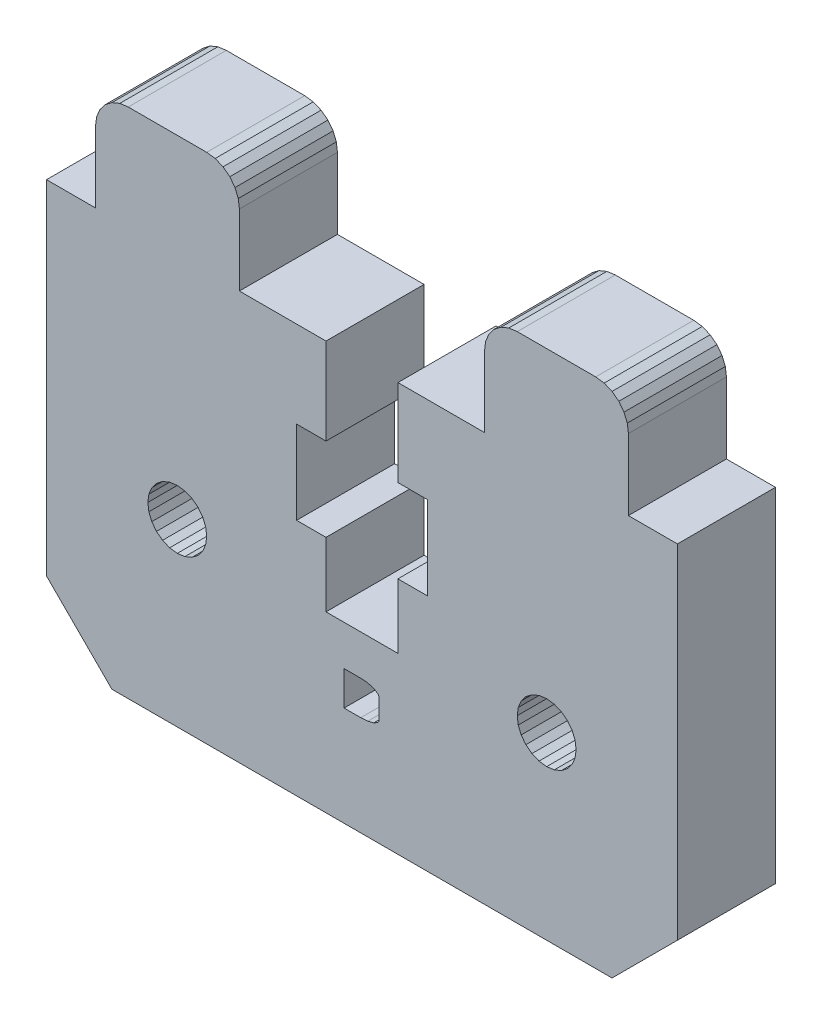
from build123d import *

# Parameters (mm, degrees)
BOSS_EXTRUDE1_DEPTH = 6


with BuildPart() as part:
    # Sketch1 → Boss-Extrude1 (new body)
    with BuildSketch(Plane.XY):
        Polygon((362.236464916, 316.694481551), (361.822251354, 316.376644305), (361.504414109, 315.962430743), (361.304613264, 315.480068833), (361.236464916, 314.962430743), (361.236464916, 310.612432852), (355.936467662, 310.612432852), (355.936467662, 305.31243403), (357.736465893, 305.31243403), (357.736465893, 300.212436266), (355.936467662, 300.212436266), (355.936467662, 296.262436443), (351.53646299, 296.262436443), (351.53646299, 300.212436266), (349.736464758, 300.212436266), (349.736464758, 305.31243403), (351.53646299, 305.31243403), (351.53646299, 310.612432852), (346.236470983, 310.612432852), (346.236470983, 314.962430743), (346.168322636, 315.480068833), (345.968521791, 315.962430743), (345.650684545, 316.376644305), (345.236470983, 316.694481551), (344.754109073, 316.894282396), (344.236470983, 316.962430743), (339.436475018, 316.962430743), (338.918836928, 316.894282396), (338.436475018, 316.694481551), (338.022261456, 316.376644305), (337.70442421, 315.962430743), (337.504623365, 315.480068833), (337.436475018, 314.962430743), (337.436475018, 310.612432852), (334.436475018, 310.612432852), (334.436475018, 289.612432852), (338.436475018, 285.612432852), (369.036459359, 285.612432852), (373.036459359, 289.612432852), (373.036459359, 310.612432852), (370.036459359, 310.612432852), (370.036459359, 314.962430743), (369.968311011, 315.480068833), (369.768510166, 315.962430743), (369.450672921, 316.376644305), (369.036459359, 316.694481551), (368.554097449, 316.894282396), (368.036459359, 316.962430743), (363.236464916, 316.962430743), (362.718826826, 316.894282396), align=None)
        Polygon((354.093152218, 291.74838599), (353.659993157, 291.717951777), (352.642224483, 291.717951777), (352.642224483, 291.718142326), (352.642224483, 293.809653378), (353.659993157, 293.809653378), (354.093152218, 293.774526901), (354.456082144, 293.669147471), (354.701943662, 293.513820442), (354.763409042, 293.425041085), (354.783897502, 293.328851168), (354.783897502, 292.161406427), (354.783897502, 292.161263515), (354.763442776, 292.066382302), (354.763409042, 292.066225822), (354.701943662, 291.980950777), (354.456082144, 291.839688629), align=None, mode=Mode.SUBTRACT)
        Polygon((340.877629291, 297.512432852), (341.163682812, 297.885225058), (341.536475018, 298.171278579), (341.970600737, 298.351099339), (342.436475018, 298.412432852), (342.902349299, 298.351099339), (343.336475018, 298.171278579), (343.709267224, 297.885225058), (343.995320745, 297.512432852), (344.175141505, 297.078307133), (344.236475018, 296.612432852), (344.175141505, 296.146558571), (343.995320745, 295.712432852), (343.709267224, 295.339640646), (343.336475018, 295.053587125), (342.902349299, 294.873766365), (342.436475018, 294.812432852), (341.970600737, 294.873766365), (341.536475018, 295.053587125), (341.163682812, 295.339640646), (340.877629291, 295.712432852), (340.697808531, 296.146558571), (340.636475018, 296.612432852), (340.697808531, 297.078307133), align=None, mode=Mode.SUBTRACT)
        Polygon((363.297792871, 296.146558571), (363.236459359, 296.612432852), (363.297792871, 297.078307133), (363.477613632, 297.512432852), (363.763667153, 297.885225058), (364.136459359, 298.171278579), (364.570585077, 298.351099339), (365.036459359, 298.412432852), (365.50233364, 298.351099339), (365.936459359, 298.171278579), (366.309251565, 297.885225058), (366.595305085, 297.512432852), (366.775125846, 297.078307133), (366.836459359, 296.612432852), (366.775125846, 296.146558571), (366.595305085, 295.712432852), (366.309251565, 295.339640646), (365.936459359, 295.053587125), (365.50233364, 294.873766365), (365.036459359, 294.812432852), (364.570585077, 294.873766365), (364.136459359, 295.053587125), (363.763667153, 295.339640646), (363.477613632, 295.712432852), align=None, mode=Mode.SUBTRACT)
    extrude(amount=BOSS_EXTRUDE1_DEPTH)


solid = part.part
